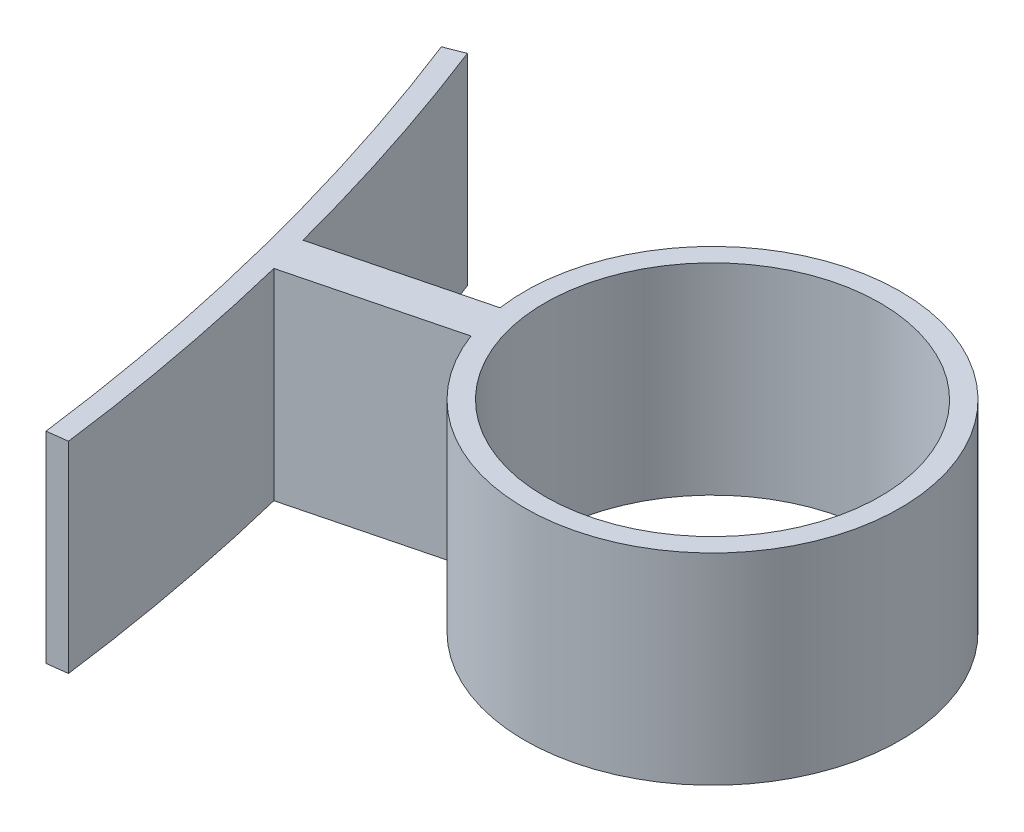
from build123d import *

# Parameters (mm, degrees)
CROQUIS1_R              = 25
SALIENTE_EXTRUIR1_DEPTH = 30


with BuildPart() as part:
    # Croquis1 → Saliente-Extruir1 (new body)
    with BuildSketch(Plane(origin=(0, 0, 0), x_dir=(1, 0, 0), z_dir=(0, 1, 0))):
        with BuildLine():
            Line((-65.797376832, 25.36524745), (-63.002208753, 26.454758997))
            ThreePointArc((-63.002208753, 26.454758997), (-56.557387251, 8.427488435), (-51.143577362, -9.935759386))
            Line((-51.143577362, -9.935759386), (-27.717597065, -3.966713114))
            ThreePointArc((-27.717597065, -3.966713114), (27.133039517, 6.913621813), (-26.236106677, -9.780935868))
            Line((-26.236106677, -9.780935868), (-49.662086973, -15.74998214))
            ThreePointArc((-49.662086973, -15.74998214), (-45.628225194, -34.464847013), (-42.660438023, -53.378081728))
            Line((-42.660438023, -53.378081728), (-45.636154363, -53.759017766))
            ThreePointArc((-45.636154363, -53.759017766), (-53.297041908, -13.580328562), (-65.797376832, 25.36524745))
        make_face()
        Circle(CROQUIS1_R, mode=Mode.SUBTRACT)
    extrude(amount=SALIENTE_EXTRUIR1_DEPTH)


solid = part.part
